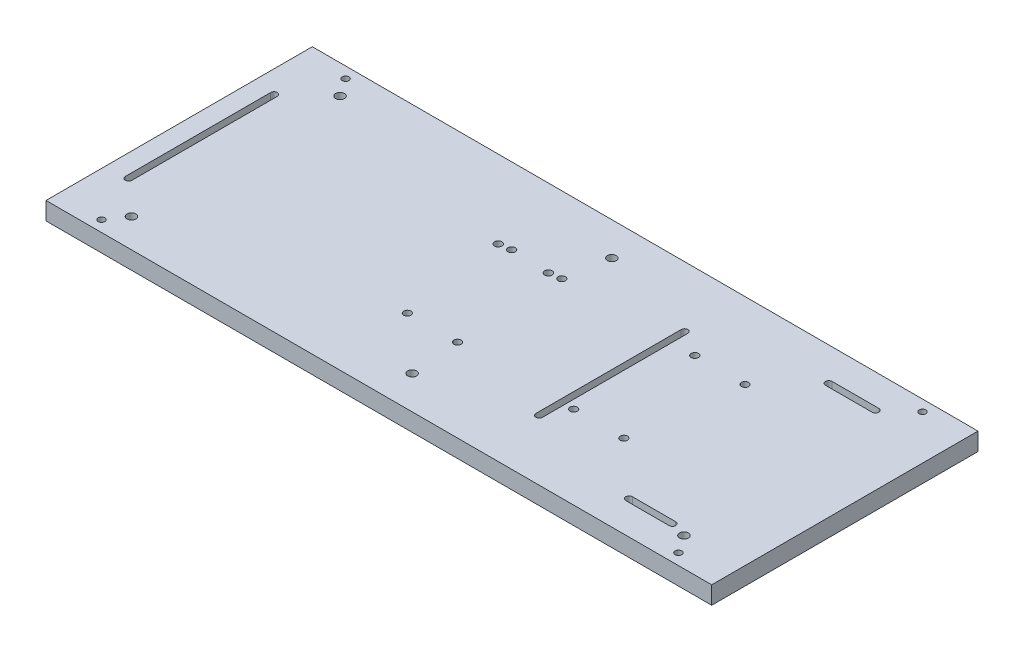
from build123d import *

# Parameters (mm, degrees)
SKETCH1_W           = 300
SKETCH1_H           = 120
BOSS_EXTRUDE1_DEPTH = 8
SKETCH2_R           = 1.636
SKETCH2_R_2         = 1.687
CUT_EXTRUDE1_DEPTH  = 8
CUT_EXTRUDE2_DEPTH  = 8
CUT_EXTRUDE3_DEPTH  = 8
SKETCH2_5_R         = 1.636
CUT_EXTRUDE4_DEPTH  = 8
SKETCH5_R           = 2
CUT_EXTRUDE5_DEPTH  = 8
SKETCH5_3_R         = 2
CUT_EXTRUDE6_DEPTH  = 8
CUT_EXTRUDE7_DEPTH  = 8
SKETCH9_R           = 1.5
CUT_EXTRUDE9_DEPTH  = 10
SKETCH8_R           = 1.5
CUT_EXTRUDE10_DEPTH = 10
SKETCH10_R          = 1.687
SKETCH10_R_2        = 1.636
CUT_EXTRUDE11_DEPTH = 10
SKETCH10_3_R        = 2
CUT_EXTRUDE12_DEPTH = 10
SKETCH10_4_R        = 2
CUT_EXTRUDE13_DEPTH = 10


with BuildPart() as part:
    # Sketch1 → Boss-Extrude1 (new body)
    with BuildSketch(Plane(origin=(0, 0, 0), x_dir=(1, 0, 0), z_dir=(0, 1, 0))):
        with Locations((83.012516048, 24.703699284)):
            Rectangle(SKETCH1_W, SKETCH1_H)
    extrude(amount=BOSS_EXTRUDE1_DEPTH)

    # Sketch2 → Cut-Extrude1 (cut)
    with BuildSketch(Plane(origin=(0, 8, 0), x_dir=(1, 0, 0), z_dir=(0, 1, 0))):
        with Locations((79.785470733, 50.392260228)):
            Circle(SKETCH2_R)
        with Locations((74.502270733, 49.630260228)):
            Circle(SKETCH2_R_2)
        with Locations((81.055470733, 2.132260228)):
            Circle(SKETCH2_R)
        with Locations((155.985470733, 2.132260228)):
            Circle(SKETCH2_R)
    extrude(amount=-CUT_EXTRUDE1_DEPTH, mode=Mode.SUBTRACT)

    # Sketch2_3 → Cut-Extrude2 (cut)
    with BuildSketch(Plane(origin=(0, 8, 0), x_dir=(1, 0, 0), z_dir=(0, 1, 0))):
        with BuildLine():
            Line((-58.487483952, -8.046300716), (-58.487483952, 57.453699284))
            ThreePointArc((-58.487483952, 57.453699284), (-56.987483952, 58.953699284), (-55.487483952, 57.453699284))
            Line((-55.487483952, 57.453699284), (-55.487483952, -8.046300716))
            ThreePointArc((-55.487483952, -8.046300716), (-56.987483952, -9.546300716), (-58.487483952, -8.046300716))
        make_face()
    extrude(amount=-CUT_EXTRUDE2_DEPTH, mode=Mode.SUBTRACT)

    # Sketch2_4 → Cut-Extrude3 (cut)
    with BuildSketch(Plane(origin=(0, 8, 0), x_dir=(1, 0, 0), z_dir=(0, 1, 0))):
        with BuildLine():
            Line((126.512516048, -8.046300716), (126.512516048, 57.453699284))
            ThreePointArc((126.512516048, 57.453699284), (128.012516048, 58.953699284), (129.512516048, 57.453699284))
            Line((129.512516048, 57.453699284), (129.512516048, -8.046300716))
            ThreePointArc((129.512516048, -8.046300716), (128.012516048, -9.546300716), (126.512516048, -8.046300716))
        make_face()
    extrude(amount=-CUT_EXTRUDE3_DEPTH, mode=Mode.SUBTRACT)

    # Sketch2_5 → Cut-Extrude4 (cut)
    with BuildSketch(Plane(origin=(0, 8, 0), x_dir=(1, 0, 0), z_dir=(0, 1, 0))):
        with Locations((162.335470733, 50.392260228)):
            Circle(SKETCH2_5_R)
    extrude(amount=-CUT_EXTRUDE4_DEPTH, mode=Mode.SUBTRACT)

    # Sketch5 → Cut-Extrude5 (cut)
    with BuildSketch(Plane(origin=(0, 8, 0), x_dir=(1, 0, 0), z_dir=(0, 1, 0))):
        with Locations((83.012516048, -20.296300716)):
            Circle(SKETCH5_R)
    extrude(amount=-CUT_EXTRUDE5_DEPTH, mode=Mode.SUBTRACT)

    # Sketch5_3 → Cut-Extrude6 (cut)
    with BuildSketch(Plane(origin=(0, 8, 0), x_dir=(1, 0, 0), z_dir=(0, 1, 0))):
        with Locations((83.012516048, 69.703699284)):
            Circle(SKETCH5_3_R)
    extrude(amount=-CUT_EXTRUDE6_DEPTH, mode=Mode.SUBTRACT)

    # Sketch6 → Cut-Extrude7 (cut)
    with BuildSketch(Plane(origin=(0, 8, 0), x_dir=(1, 0, 0), z_dir=(0, 1, 0))):
        with BuildLine():
            Line((180.768543767, 71.203699284), (201.803443745, 71.203699284))
            ThreePointArc((201.803443745, 71.203699284), (203.303443745, 69.703699284), (201.803443745, 68.203699284))
            Line((201.803443745, 68.203699284), (180.768543767, 68.203699284))
            ThreePointArc((180.768543767, 68.203699284), (179.268543767, 69.703699284), (180.768543767, 71.203699284))
        make_face()
        with BuildLine():
            Line((180.768543767, -18.796300716), (200.303443745, -18.796300716))
            ThreePointArc((200.303443745, -18.796300716), (201.803443745, -20.296300716), (200.303443745, -21.796300716))
            Line((200.303443745, -21.796300716), (180.768543767, -21.796300716))
            ThreePointArc((180.768543767, -21.796300716), (179.268543767, -20.296300716), (180.768543767, -18.796300716))
        make_face()
    extrude(amount=-CUT_EXTRUDE7_DEPTH, mode=Mode.SUBTRACT)

    # Sketch9 → Cut-Extrude9 (cut)
    with BuildSketch(Plane.XZ):
        with Locations((213.012516048, -79.703699284)):
            Circle(SKETCH9_R)
        with Locations((-46.987483952, -79.703699284)):
            Circle(SKETCH9_R)
    extrude(amount=-CUT_EXTRUDE9_DEPTH, mode=Mode.SUBTRACT)

    # Sketch8 → Cut-Extrude10 (cut)
    with BuildSketch(Plane(origin=(0, 8, 0), x_dir=(1, 0, 0), z_dir=(0, 1, 0))):
        with Locations((-46.987483952, -30.296300716)):
            Circle(SKETCH8_R)
        with Locations((213.012516048, -30.296300716)):
            Circle(SKETCH8_R)
    extrude(amount=-CUT_EXTRUDE10_DEPTH, mode=Mode.SUBTRACT)

    # Sketch10 → Cut-Extrude11 (cut)
    with BuildSketch(Plane.XZ):
        with Locations((51.875302079, -49.630260228)):
            Circle(SKETCH10_R)
        with Locations((57.158502079, -50.392260228)):
            Circle(SKETCH10_R_2)
        with Locations((58.428502079, -2.132260228)):
            Circle(SKETCH10_R_2)
        with Locations((139.708502079, -50.392260228)):
            Circle(SKETCH10_R_2)
        with Locations((133.358502079, -2.132260228)):
            Circle(SKETCH10_R_2)
    extrude(amount=-CUT_EXTRUDE11_DEPTH, mode=Mode.SUBTRACT)

    # Sketch10_3 → Cut-Extrude12 (cut)
    with BuildSketch(Plane.XZ):
        with Locations((207.512516048, 22.296300716)):
            Circle(SKETCH10_3_R)
    extrude(amount=-CUT_EXTRUDE12_DEPTH, mode=Mode.SUBTRACT)

    # Sketch10_4 → Cut-Extrude13 (cut)
    with BuildSketch(Plane.XZ):
        with Locations((-41.487483952, 22.296300716)):
            Circle(SKETCH10_4_R)
        with Locations((-41.487483952, -71.703699284)):
            Circle(SKETCH10_4_R)
    extrude(amount=-CUT_EXTRUDE13_DEPTH, mode=Mode.SUBTRACT)


solid = part.part
